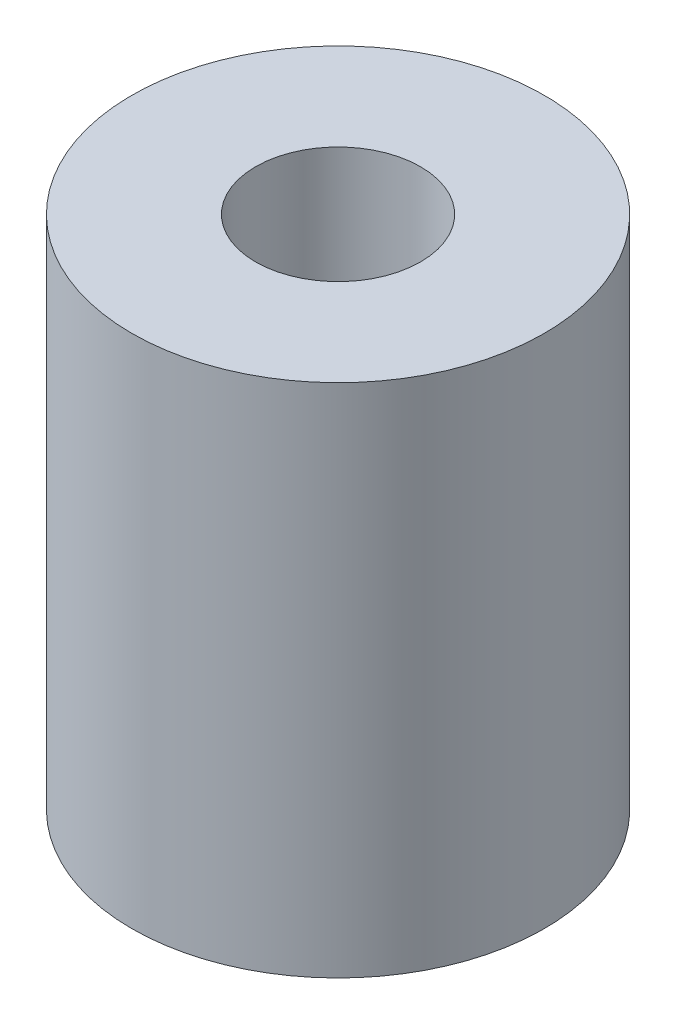
from build123d import *

# Parameters (mm, degrees)
SKETCH1_R           = 10
BOSS_EXTRUDE1_DEPTH = 25
SKETCH2_R           = 4
CUT_EXTRUDE1_DEPTH  = 9
SKETCH3_R           = 2.5
CUT_EXTRUDE2_DEPTH  = 11


with BuildPart() as part:
    # Sketch1 → Boss-Extrude1 (new body)
    with BuildSketch(Plane(origin=(0, 0, 0), x_dir=(1, 0, 0), z_dir=(0, 1, 0))):
        Circle(SKETCH1_R)
    extrude(amount=BOSS_EXTRUDE1_DEPTH)

    # Sketch2 → Cut-Extrude1 (cut)
    with BuildSketch(Plane(origin=(0, 25, 0), x_dir=(1, 0, 0), z_dir=(0, 1, 0))):
        Circle(SKETCH2_R)
    extrude(amount=-CUT_EXTRUDE1_DEPTH, mode=Mode.SUBTRACT)

    # Sketch3 → Cut-Extrude2 (cut)
    with BuildSketch(Plane(origin=(0, 0, 0), x_dir=(-1, 0, 0), z_dir=(0, -1, 0))):
        Circle(SKETCH3_R)
    extrude(amount=-CUT_EXTRUDE2_DEPTH, mode=Mode.SUBTRACT)


solid = part.part
